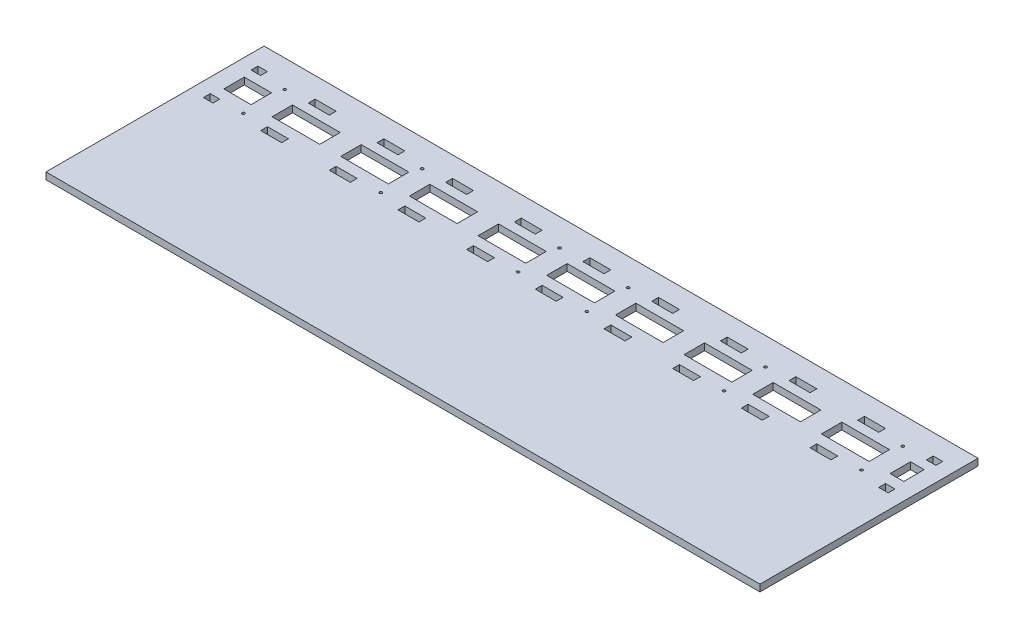
from build123d import *

# Parameters (mm, degrees)
SKETCH1_W           = 1330.706
SKETCH1_H           = 406.4
BOSS_EXTRUDE1_DEPTH = 12.7
SKETCH3_R           = 2.54
SKETCH3_W           = 50.8
SKETCH3_H           = 38.1
SKETCH3_W_2         = 88.9
SKETCH3_W_3         = 17.78
SKETCH3_H_2         = 12.7
SKETCH3_W_4         = 25.4
SKETCH3_W_5         = 39.0906
CUT_EXTRUDE2_DEPTH  = 13.7


with BuildPart() as part:
    # Sketch1 → Boss-Extrude1 (new body)
    with BuildSketch(Plane(origin=(0, 0, 0), x_dir=(1, 0, 0), z_dir=(0, 1, 0))):
        with Locations((665.353, 203.2)):
            Rectangle(SKETCH1_W, SKETCH1_H)
    extrude(amount=BOSS_EXTRUDE1_DEPTH)

    # Sketch3 → Cut-Extrude2 (cut, through all)
    with BuildSketch(Plane.XZ):
        with Locations((89.3953, -278.5618)):
            Circle(SKETCH3_R)
        with Locations((89.3953, -355.6)):
            Circle(SKETCH3_R)
        with Locations((345.3765, -278.5618)):
            Circle(SKETCH3_R)
        with Locations((345.3765, -355.6)):
            Circle(SKETCH3_R)
        with Locations((601.3577, -278.5618)):
            Circle(SKETCH3_R)
        with Locations((601.3577, -355.6)):
            Circle(SKETCH3_R)
        with Locations((729.3483, -278.5618)):
            Circle(SKETCH3_R)
        with Locations((729.3483, -355.6)):
            Circle(SKETCH3_R)
        with Locations((985.3295, -278.5618)):
            Circle(SKETCH3_R)
        with Locations((985.3295, -355.6)):
            Circle(SKETCH3_R)
        with Locations((1241.3107, -278.5618)):
            Circle(SKETCH3_R)
        with Locations((1241.3107, -355.6)):
            Circle(SKETCH3_R)
        with Locations((57.15, -318.77)):
            Rectangle(SKETCH3_W, SKETCH3_H)
        with Locations((294.0812, -318.77)):
            Rectangle(SKETCH3_W_2, SKETCH3_H)
        with Locations((166.0906, -318.77)):
            Rectangle(SKETCH3_W_2, SKETCH3_H)
        with Locations((35.56, -361.95)):
            Rectangle(SKETCH3_W_3, SKETCH3_H_2)
        with Locations((422.0718, -318.77)):
            Rectangle(SKETCH3_W_2, SKETCH3_H)
        with Locations((550.0624, -318.77)):
            Rectangle(SKETCH3_W_2, SKETCH3_H)
        with Locations((678.053, -318.77)):
            Rectangle(SKETCH3_W_2, SKETCH3_H)
        with Locations((806.0436, -318.77)):
            Rectangle(SKETCH3_W_2, SKETCH3_H)
        with Locations((934.0342, -318.77)):
            Rectangle(SKETCH3_W_2, SKETCH3_H)
        with Locations((1062.0248, -318.77)):
            Rectangle(SKETCH3_W_2, SKETCH3_H)
        with Locations((1190.0154, -318.77)):
            Rectangle(SKETCH3_W_2, SKETCH3_H)
        with Locations((1286.256, -318.77)):
            Rectangle(SKETCH3_W_4, SKETCH3_H)
        with Locations((408.8765, -273.05)):
            Rectangle(SKETCH3_W_5, SKETCH3_H_2)
        with Locations((35.56, -273.05)):
            Rectangle(SKETCH3_W_3, SKETCH3_H_2)
        with Locations((152.8953, -273.05)):
            Rectangle(SKETCH3_W_5, SKETCH3_H_2)
        with Locations((152.8953, -361.95)):
            Rectangle(SKETCH3_W_5, SKETCH3_H_2)
        with Locations((280.8859, -273.05)):
            Rectangle(SKETCH3_W_5, SKETCH3_H_2)
        with Locations((280.8859, -361.95)):
            Rectangle(SKETCH3_W_5, SKETCH3_H_2)
        with Locations((408.8765, -361.95)):
            Rectangle(SKETCH3_W_5, SKETCH3_H_2)
        with Locations((536.8671, -361.95)):
            Rectangle(SKETCH3_W_5, SKETCH3_H_2)
        with Locations((536.8671, -273.05)):
            Rectangle(SKETCH3_W_5, SKETCH3_H_2)
        with Locations((664.8577, -361.95)):
            Rectangle(SKETCH3_W_5, SKETCH3_H_2)
        with Locations((664.8577, -273.05)):
            Rectangle(SKETCH3_W_5, SKETCH3_H_2)
        with Locations((792.8483, -273.05)):
            Rectangle(SKETCH3_W_5, SKETCH3_H_2)
        with Locations((920.8389, -361.95)):
            Rectangle(SKETCH3_W_5, SKETCH3_H_2)
        with Locations((792.8483, -361.95)):
            Rectangle(SKETCH3_W_5, SKETCH3_H_2)
        with Locations((920.8389, -273.05)):
            Rectangle(SKETCH3_W_5, SKETCH3_H_2)
        with Locations((1048.8295, -361.95)):
            Rectangle(SKETCH3_W_5, SKETCH3_H_2)
        with Locations((1048.8295, -273.05)):
            Rectangle(SKETCH3_W_5, SKETCH3_H_2)
        with Locations((1176.8201, -273.05)):
            Rectangle(SKETCH3_W_5, SKETCH3_H_2)
        with Locations((1176.8201, -361.95)):
            Rectangle(SKETCH3_W_5, SKETCH3_H_2)
        with Locations((1294.1554, -361.95)):
            Rectangle(SKETCH3_W_3, SKETCH3_H_2)
        with Locations((1294.1554, -273.05)):
            Rectangle(SKETCH3_W_3, SKETCH3_H_2)
    extrude(amount=-CUT_EXTRUDE2_DEPTH, mode=Mode.SUBTRACT)


solid = part.part
